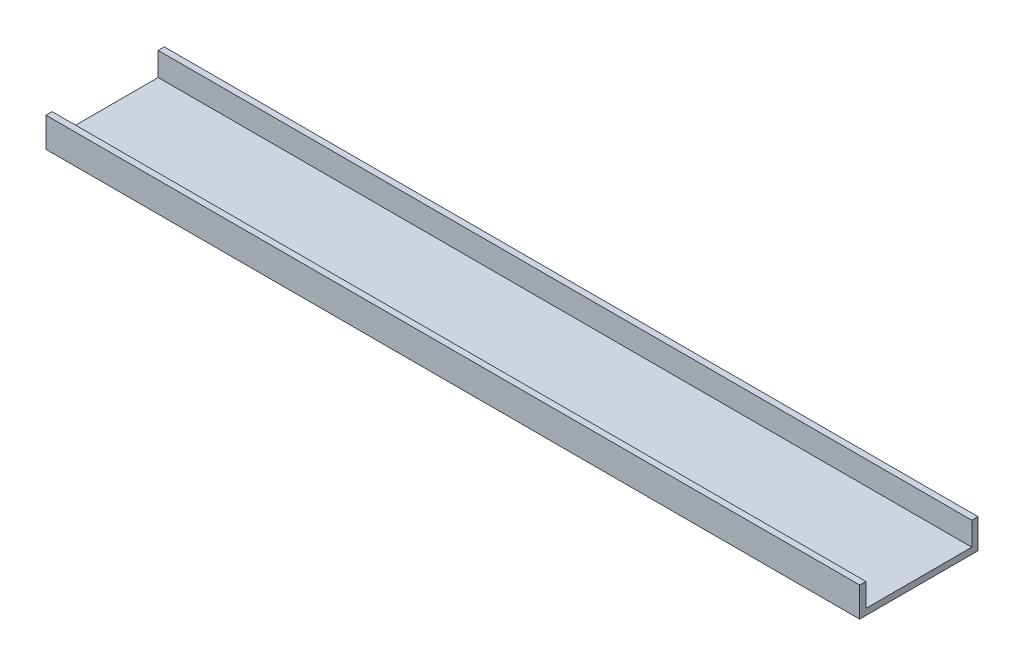
from build123d import *

# Parameters (mm, degrees)
SKETCH1_W               = 330
SKETCH1_H               = 48
BOSS_EXTRUDE1_DEPTH     = 12
SKETCH2_W               = 43
SKETCH2_H               = 9.5
CUT_EXTRUDE1_DEPTH      = 166
CUT_EXTRUDE1_DEPTH_BACK = 166


with BuildPart() as part:
    # Sketch1 → Boss-Extrude1 (new body)
    with BuildSketch(Plane(origin=(0, 0, 0), x_dir=(1, 0, 0), z_dir=(0, 1, 0))):
        Rectangle(SKETCH1_W, SKETCH1_H)
    extrude(amount=BOSS_EXTRUDE1_DEPTH)

    # Sketch2 → Cut-Extrude1 (cut, two sides)
    with BuildSketch(Plane(origin=(0, 0, 0), x_dir=(0, 0, -1), z_dir=(1, 0, 0))) as cut_extrude1_sk:
        with Locations((0, 7.25)):
            Rectangle(SKETCH2_W, SKETCH2_H)
    extrude(amount=CUT_EXTRUDE1_DEPTH, mode=Mode.SUBTRACT)
    extrude(cut_extrude1_sk.sketch, amount=-CUT_EXTRUDE1_DEPTH_BACK, mode=Mode.SUBTRACT)


solid = part.part
